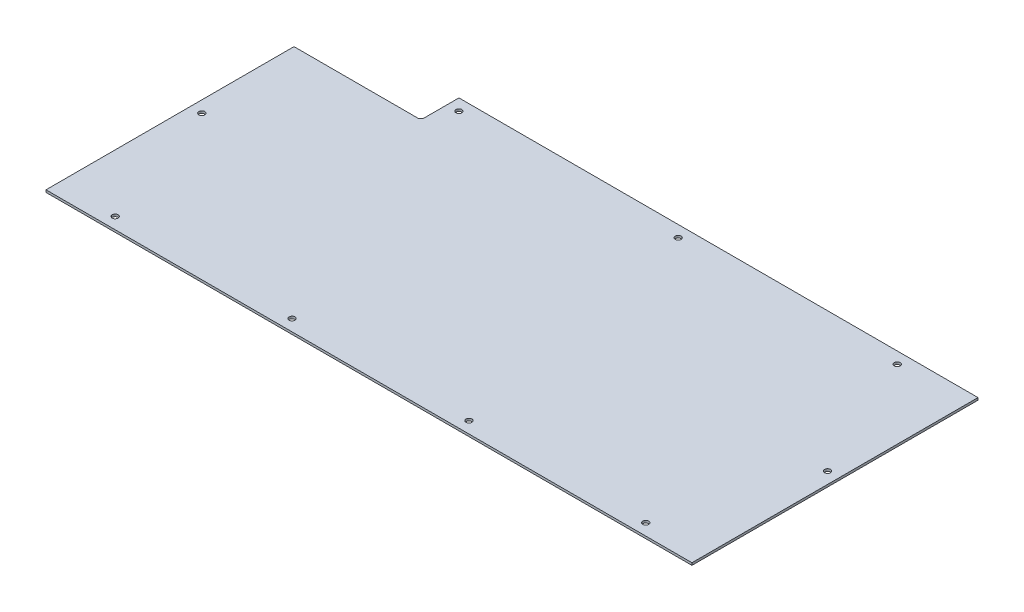
from build123d import *

# Parameters (mm, degrees)
SKETCH1_R           = 2.55
BOSS_EXTRUDE1_DEPTH = 2


with BuildPart() as part:
    # Sketch1 → Boss-Extrude1 (new body)
    with BuildSketch(Plane(origin=(0, 0, 0), x_dir=(1, 0, 0), z_dir=(0, 1, 0))):
        with BuildLine():
            Line((-288.144382289, 87.393439394), (-181.144388941, 87.393202129))
            ThreePointArc((-181.144388941, 87.393202129), (-179.023064297, 88.271879434), (-178.144382289, 90.393202129))
            Line((-178.144382289, 90.393202129), (-178.144382289, 120.393202129))
            Line((-178.144382289, 120.393202129), (271.855617711, 120.393202129))
            Line((271.855617711, 120.393202129), (271.855617711, -127.606797871))
            Line((271.855617711, -127.606797871), (-288.144382289, -127.606797871))
            Line((-288.144382289, -127.606797871), (-288.144382289, 87.393439394))
        make_face()
        with Locations((211.855617711, 110.393202129)):
            Circle(SKETCH1_R, mode=Mode.SUBTRACT)
        with Locations((-168.144382289, 110.393202129)):
            Circle(SKETCH1_R, mode=Mode.SUBTRACT)
        with Locations((21.855617711, 110.393202129)):
            Circle(SKETCH1_R, mode=Mode.SUBTRACT)
        with Locations((-238.144382289, -117.606797871)):
            Circle(SKETCH1_R, mode=Mode.SUBTRACT)
        with Locations((-84.811048956, -117.606797871)):
            Circle(SKETCH1_R, mode=Mode.SUBTRACT)
        with Locations((68.522284378, -117.606797871)):
            Circle(SKETCH1_R, mode=Mode.SUBTRACT)
        with Locations((221.855617711, -117.606797871)):
            Circle(SKETCH1_R, mode=Mode.SUBTRACT)
        with Locations((261.855617711, 0)):
            Circle(SKETCH1_R, mode=Mode.SUBTRACT)
        with Locations((-278.144382289, -2.55)):
            Circle(SKETCH1_R, mode=Mode.SUBTRACT)
    extrude(amount=BOSS_EXTRUDE1_DEPTH)


solid = part.part
